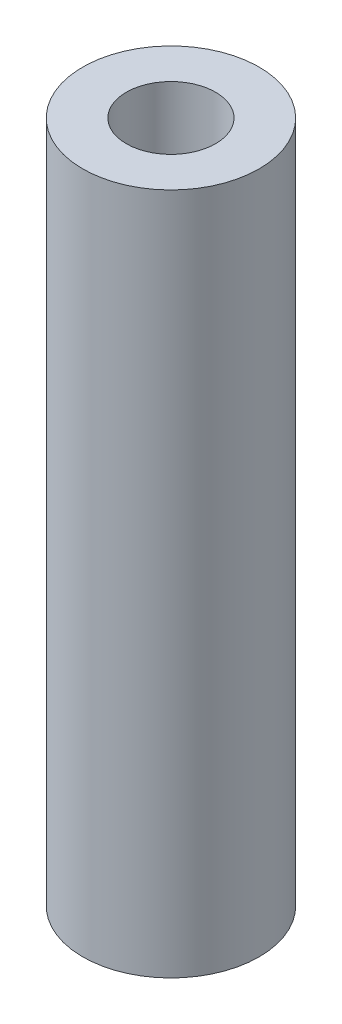
from build123d import *

# Parameters (mm, degrees)
SKETCH1_R           = 12.15
SKETCH1_R_2         = 6.15
EXTRUDE_THIN1_DEPTH = 94


with BuildPart() as part:
    # Sketch1 → Extrude-Thin1 (new body)
    with BuildSketch(Plane(origin=(0, 0, 0), x_dir=(1, 0, 0), z_dir=(0, 1, 0))):
        Circle(SKETCH1_R)
        Circle(SKETCH1_R_2, mode=Mode.SUBTRACT)
    extrude(amount=EXTRUDE_THIN1_DEPTH)


solid = part.part
